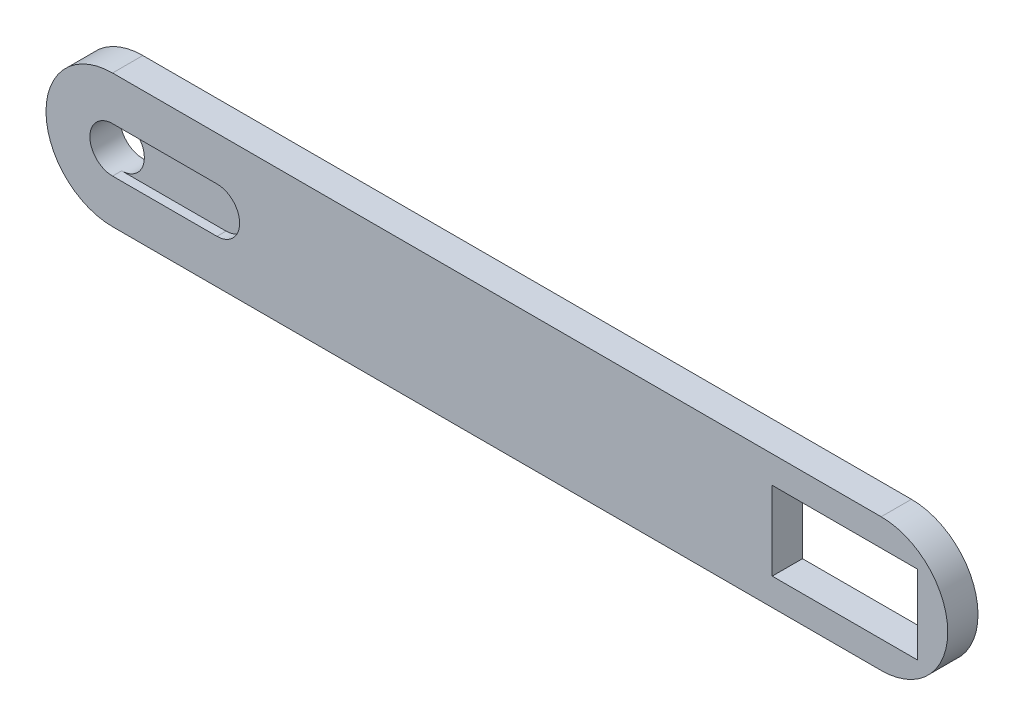
from build123d import *

# Parameters (mm, degrees)
SKETCH1_R           = 3.75
SKETCH1_W           = 24
SKETCH1_H           = 13
BOSS_EXTRUDE1_DEPTH = 5
CUT_EXTRUDE1_DEPTH  = 1.5


with BuildPart() as part:
    # Sketch1 → Boss-Extrude1 (new body)
    with BuildSketch(Plane.XY):
        with BuildLine():
            ThreePointArc((0, 22), (-11, 11), (0, 0))
            Line((0, 0), (127, 0))
            ThreePointArc((127, 0), (138, 11), (127, 22))
            Line((127, 22), (0, 22))
        make_face()
        with Locations((0, 11)):
            Circle(SKETCH1_R, mode=Mode.SUBTRACT)
        with Locations((121, 11)):
            Rectangle(SKETCH1_W, SKETCH1_H, mode=Mode.SUBTRACT)
    extrude(amount=BOSS_EXTRUDE1_DEPTH)

    # Sketch3 → Cut-Extrude1 (cut)
    with BuildSketch(Plane.XY.offset(5)):
        with BuildLine():
            Line((0, 14.75), (17.25, 14.75))
            ThreePointArc((17.25, 14.75), (21, 11), (17.25, 7.25))
            Line((17.25, 7.25), (0, 7.25))
            ThreePointArc((0, 7.25), (3.75, 11), (0, 14.75))
        make_face()
    extrude(amount=-CUT_EXTRUDE1_DEPTH, mode=Mode.SUBTRACT)


solid = part.part
